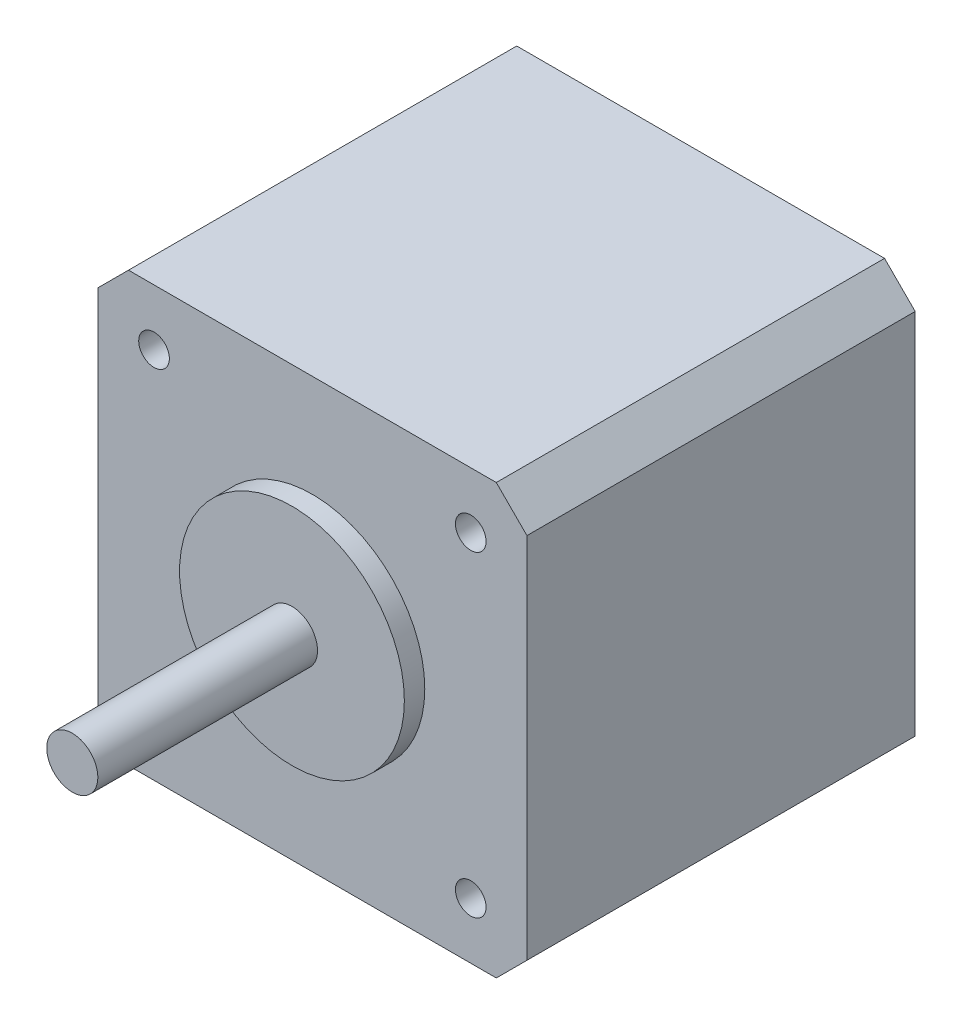
from build123d import *

# Parameters (mm, degrees)
SKETCH1_W           = 42
SKETCH1_H           = 42
BOSS_EXTRUDE1_DEPTH = 38
SKETCH2_R           = 11
BOSS_EXTRUDE2_DEPTH = 2
SKETCH3_R           = 2.5
BOSS_EXTRUDE3_DEPTH = 21.5
SKETCH4_R           = 1.5
CUT_EXTRUDE1_DEPTH  = 4.5
CHAMFER1_SIZE       = 3


with BuildPart() as part:
    # Sketch1 → Boss-Extrude1 (new body)
    with BuildSketch(Plane.XY):
        Rectangle(SKETCH1_W, SKETCH1_H)
    extrude(amount=BOSS_EXTRUDE1_DEPTH)

    # Sketch2 → Boss-Extrude2 (add)
    with BuildSketch(Plane.XY.offset(38)):
        Circle(SKETCH2_R)
    extrude(amount=BOSS_EXTRUDE2_DEPTH)

    # Sketch3 → Boss-Extrude3 (add)
    with BuildSketch(Plane.XY.offset(40)):
        Circle(SKETCH3_R)
    extrude(amount=BOSS_EXTRUDE3_DEPTH)

    # Sketch4 → Cut-Extrude1 (cut)
    with BuildSketch(Plane.XY.offset(38)):
        with Locations((15.5, 15.5)):
            Circle(SKETCH4_R)
        with Locations((15.5, -15.5)):
            Circle(SKETCH4_R)
        with Locations((-15.5, -15.5)):
            Circle(SKETCH4_R)
        with Locations((-15.5, 15.5)):
            Circle(SKETCH4_R)
    extrude(amount=-CUT_EXTRUDE1_DEPTH, mode=Mode.SUBTRACT)

    # Chamfer1
    chamfer1_edges = [part.edges().sort_by_distance(p)[0] for p in [
        (21, -21, 19),
        (-21, -21, 19),
        (-21, 21, 19),
        (21, 21, 19),
    ]]
    chamfer(chamfer1_edges, length=CHAMFER1_SIZE)


solid = part.part
